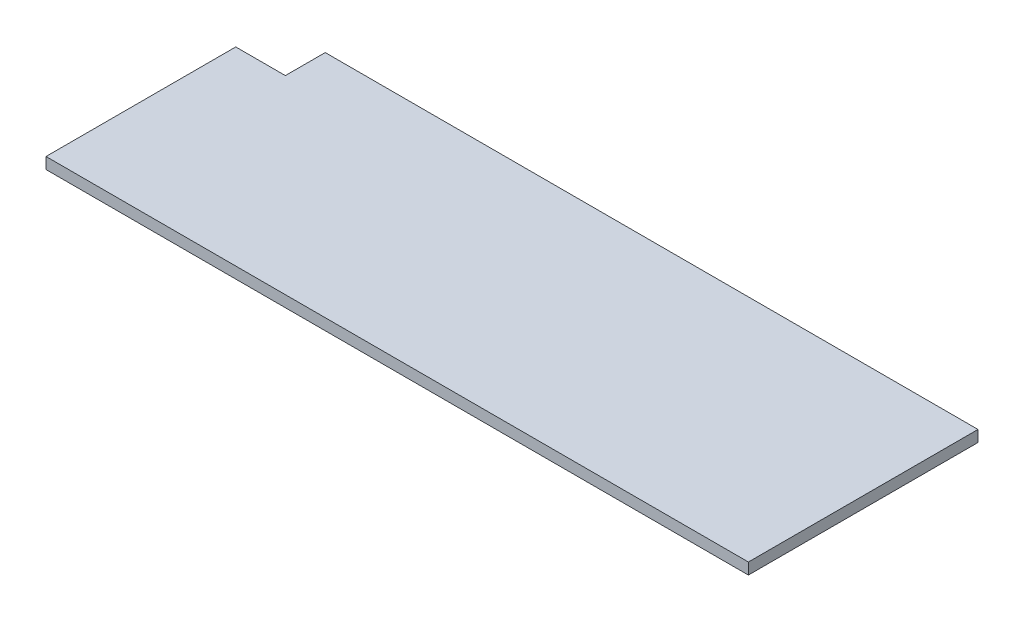
from build123d import *

# Parameters (mm, degrees)
BOSS_EXTRUDE1_DEPTH = 2.67


with BuildPart() as part:
    # Sketch1 → Boss-Extrude1 (new body)
    with BuildSketch(Plane(origin=(0, 0, 0), x_dir=(1, 0, 0), z_dir=(0, 1, 0))):
        Polygon((0, 0), (0, 44.75), (11.7, 44.75), (11.7, 54.15), (165.65, 54.15), (165.65, 0), align=None)
    extrude(amount=BOSS_EXTRUDE1_DEPTH)


solid = part.part
